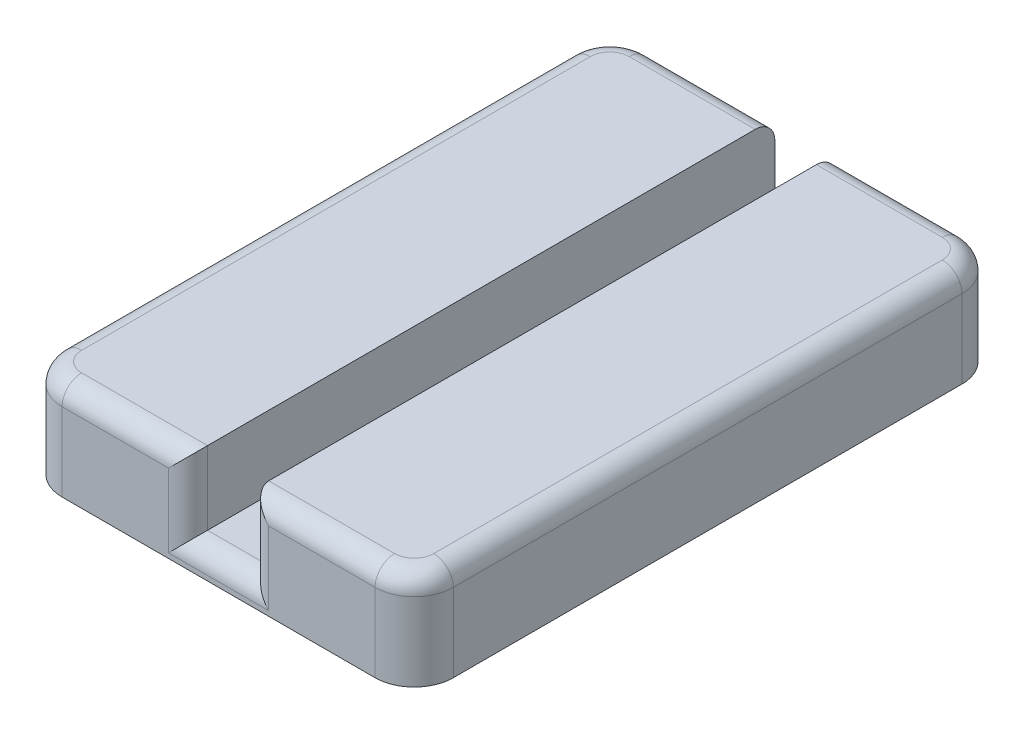
from build123d import *

# Parameters (mm, degrees)
BOSS_EXTRUDE1_DEPTH = 6.35
SKETCH2_W           = 3.96875
SKETCH2_H           = 31.75
CUT_EXTRUDE1_DEPTH  = 4.7625
FILLET1_R           = 1.27
SKETCH3_W           = 4.462087674
SKETCH3_H           = 1.522359324
SKETCH3_W_2         = 4.462087673
CUT_EXTRUDE2_DEPTH  = 0.79375


with BuildPart() as part:
    # Sketch1 → Boss-Extrude1 (new body)
    with BuildSketch(Plane(origin=(0, 0, 0), x_dir=(1, 0, 0), z_dir=(0, 1, 0))):
        with BuildLine():
            Line((14.684375, 38.1), (22.86, 38.1))
            ThreePointArc((22.86, 38.1), (24.656051224, 37.356051224), (25.4, 35.56))
            Line((25.4, 35.56), (25.4, 2.54))
            ThreePointArc((25.4, 2.54), (24.656051224, 0.743948776), (22.86, 0))
            Line((22.86, 0), (2.54, 0))
            ThreePointArc((2.54, 0), (0.743948776, 0.743948776), (0, 2.54))
            Line((0, 2.54), (0, 35.56))
            ThreePointArc((0, 35.56), (0.743948776, 37.356051224), (2.54, 38.1))
            Line((2.54, 38.1), (10.715625, 38.1))
            Line((10.715625, 38.1), (10.715625, 31.75))
            Line((10.715625, 31.75), (14.684375, 31.75))
            Line((14.684375, 31.75), (14.684375, 38.1))
        make_face()
    extrude(amount=BOSS_EXTRUDE1_DEPTH)

    # Sketch2 → Cut-Extrude1 (cut)
    with BuildSketch(Plane(origin=(0, 6.35, 0), x_dir=(1, 0, 0), z_dir=(0, 1, 0))):
        with Locations((12.7, 15.875)):
            Rectangle(SKETCH2_W, SKETCH2_H)
    extrude(amount=-CUT_EXTRUDE1_DEPTH, mode=Mode.SUBTRACT)

    # Fillet1
    fillet1_edges = [part.edges().sort_by_distance(p)[0] for p in [
        (0.743948776, 6.35, -37.356051224),
        (6.6278125, 6.35, -38.1),
        (18.7721875, 6.35, -38.1),
        (18.7721875, 6.35, 0),
        (24.656051224, 6.35, -37.356051224),
        (10.715625, 3.96875, 0),
        (12.7, 1.5875, -31.75),
        (25.4, 6.35, -19.05),
        (12.7, 1.5875, 0),
        (14.684375, 3.96875, 0),
        (24.656051224, 6.35, -0.743948776),
        (6.6278125, 6.35, 0),
        (0.743948776, 6.35, -0.743948776),
        (0, 6.35, -19.05),
    ]]
    fillet(fillet1_edges, radius=FILLET1_R)

    # Sketch3 → Cut-Extrude2 (cut)
    with BuildSketch(Plane.XZ):
        with BuildLine():
            add(Edge.make_bspline(
                [(20.770912427, -33.576184894), (20.716776575, -33.575961936), (20.612603721, -33.5755329), (20.46221534, -33.574104371), (20.324123043, -33.570966146), (20.198357128, -33.565906255), (20.0851548, -33.56021535), (19.983936013, -33.553953657), (19.895010405, -33.545929307), (19.79312919, -33.533339086), (19.675339314, -33.508045408), (19.542562083, -33.453162316), (19.415773604, -33.377459207), (19.296119441, -33.28060062), (19.187162712, -33.162711763), (19.090314389, -33.025739765), (19.00765376, -32.869592526), (18.939057469, -32.695081183), (18.885695016, -32.503668238), (18.846232758, -32.297148185), (18.823553351, -32.075383853), (18.820384009, -31.922639669), (18.81874907, -31.843844974)],
                knots=[0, 0, 0, 0, 0.000162409, 0.000312521, 0.00045118, 0.000576773, 0.000690111, 0.000791213, 0.000880994, 0.000957909, 0.00109919, 0.001240844, 0.00138686, 0.001540837, 0.001701021, 0.001866932, 0.002042704, 0.002229747, 0.002428381, 0.002637991, 0.002859827, 0.003096198, 0.003096198, 0.003096198, 0.003096198], degree=3))
            add(Edge.make_bspline(
                [(18.81874907, -31.843844974), (18.820056819, -31.768593244), (18.822606968, -31.621850102), (18.845623822, -31.407818714), (18.880613937, -31.205347102), (18.932464861, -31.015691402), (18.997496906, -30.84012306), (19.079619825, -30.682160196), (19.174340805, -30.540767403), (19.285724344, -30.420603753), (19.405691262, -30.319794274), (19.531750246, -30.239314331), (19.664152178, -30.183593443), (19.780329143, -30.155581686), (19.881394574, -30.143599817), (19.970235853, -30.134421964), (20.072273761, -30.127228316), (20.186878161, -30.121863165), (20.314552553, -30.116688035), (20.455107258, -30.113589402), (20.608775896, -30.112153355), (20.715409479, -30.111726982), (20.770912427, -30.111505054)],
                knots=[0, 0, 0, 0, 0.000225686, 0.000440094, 0.000645075, 0.00084147, 0.001029153, 0.001205613, 0.001374422, 0.001538129, 0.001695345, 0.001843499, 0.001985023, 0.002124282, 0.002200383, 0.002290243, 0.00239222, 0.002507196, 0.002634428, 0.002775547, 0.00292894, 0.00309545, 0.00309545, 0.00309545, 0.00309545], degree=3))
            Line((20.770912427, -30.111505054), (21.538653983, -30.111505054))
            add(Edge.make_bspline(
                [(21.538653983, -30.111505054), (21.592789272, -30.1117433), (21.697234431, -30.112202958), (21.847630365, -30.113430259), (21.985688596, -30.11718283), (22.111262665, -30.120348252), (22.224650246, -30.12784749), (22.325914729, -30.133573998), (22.414823773, -30.141831713), (22.516437137, -30.154333705), (22.634237386, -30.179638329), (22.766964482, -30.234572303), (22.893767225, -30.30993937), (23.01263834, -30.407659357), (23.122495508, -30.524631734), (23.219175047, -30.662011072), (23.30201392, -30.818059389), (23.370184173, -30.992772567), (23.425311838, -31.183754367), (23.462628775, -31.390734149), (23.487442826, -31.612207153), (23.489669148, -31.765029295), (23.49081734, -31.843844974)],
                knots=[0, 0, 0, 0, 0.000162409, 0.000313341, 0.00045118, 0.000576743, 0.000690126, 0.000792047, 0.000881011, 0.000957926, 0.001099207, 0.001240861, 0.001386877, 0.001540217, 0.001700961, 0.001866872, 0.002042644, 0.002229686, 0.002428546, 0.002638004, 0.002859926, 0.003096269, 0.003096269, 0.003096269, 0.003096269], degree=3))
            add(Edge.make_bspline(
                [(23.49081734, -31.843844974), (23.489480685, -31.919091495), (23.486874166, -32.065824479), (23.464252931, -32.279976538), (23.427779674, -32.482498911), (23.376439542, -32.672201529), (23.31202572, -32.84792467), (23.229956548, -33.005552517), (23.13497101, -33.146965677), (23.024088338, -33.267830417), (22.90410273, -33.36883421), (22.77756224, -33.448224732), (22.645212955, -33.504309591), (22.528668317, -33.532039525), (22.427622747, -33.544046719), (22.339061884, -33.553321076), (22.237291771, -33.560450689), (22.122688525, -33.565830216), (21.995013771, -33.571000841), (21.854459179, -33.574100872), (21.700790507, -33.5755365), (21.594156928, -33.575962934), (21.538653983, -33.576184894)],
                knots=[0, 0, 0, 0, 0.000225686, 0.000440094, 0.000645221, 0.000842407, 0.001029034, 0.001205493, 0.001374303, 0.001538614, 0.001695831, 0.001843551, 0.001985074, 0.002125131, 0.002201232, 0.002290275, 0.002392252, 0.002507229, 0.002634461, 0.00277558, 0.002928973, 0.003095483, 0.003095483, 0.003095483, 0.003095483], degree=3))
            Line((21.538653983, -33.576184894), (20.770912427, -33.576184894))
        make_face()
        with BuildLine():
            add(Edge.make_bspline(
                [(22.26128252, -32.05382557), (22.286435978, -32.053591122), (22.334560789, -32.053142563), (22.403226389, -32.051892174), (22.464729911, -32.048317769), (22.519234309, -32.044687332), (22.566509651, -32.038727219), (22.606928031, -32.032740878), (22.639778769, -32.024473408), (22.673717551, -32.013260872), (22.707498513, -31.991035252), (22.736526032, -31.95322813), (22.753120401, -31.904697385), (22.754917642, -31.869406837), (22.755885253, -31.850406868)],
                knots=[0, 0, 0, 0, 7.5466e-05, 0.000144386, 0.000205991, 0.000260282, 0.000308201, 0.000348924, 0.000382743, 0.000409724, 0.000455906, 0.000501516, 0.00055029, 0.000607177, 0.000607177, 0.000607177, 0.000607177], degree=3))
            add(Edge.make_bspline(
                [(22.755885253, -31.850406868), (22.755326946, -31.833882053), (22.75425251, -31.802080759), (22.739635876, -31.757814511), (22.716894598, -31.719273361), (22.689616874, -31.692223987), (22.659716096, -31.674567567), (22.628265635, -31.663610736), (22.588216067, -31.655247606), (22.53988565, -31.646593098), (22.482505713, -31.641864236), (22.416676993, -31.636291142), (22.341948057, -31.634384162), (22.289169395, -31.634044072), (22.26128252, -31.633864378)],
                knots=[0, 0, 0, 0, 4.9385e-05, 9.5039e-05, 0.000138084, 0.000182747, 0.00020849, 0.000241707, 0.000282099, 0.000331183, 0.000388886, 0.000454689, 0.000529371, 0.00061304, 0.00061304, 0.00061304, 0.00061304], degree=3))
            Line((22.26128252, -31.633864378), (20.136049218, -31.633864378))
            add(Edge.make_bspline(
                [(20.136049218, -31.633864378), (20.104605962, -31.634064235), (20.044722883, -31.634444859), (19.959685902, -31.636122178), (19.884194165, -31.63830417), (19.818233914, -31.642115634), (19.761979213, -31.648274489), (19.714786702, -31.653439147), (19.67703549, -31.660337321), (19.640585394, -31.671757801), (19.603987984, -31.69226679), (19.573494103, -31.731405445), (19.556167712, -31.782636525), (19.554555924, -31.820185205), (19.553681158, -31.840564027)],
                knots=[0, 0, 0, 0, 9.4331e-05, 0.000179651, 0.000255153, 0.0003209, 0.000377787, 0.000424892, 0.000463338, 0.000492649, 0.000539352, 0.000586621, 0.000637989, 0.000698957, 0.000698957, 0.000698957, 0.000698957], degree=3))
            add(Edge.make_bspline(
                [(19.553681158, -31.840564027), (19.554596703, -31.861570568), (19.556302052, -31.900698559), (19.577643484, -31.953205458), (19.612242654, -31.99404748), (19.653422657, -32.01502396), (19.694324836, -32.026466759), (19.735110971, -32.033051476), (19.784820604, -32.040052409), (19.844044269, -32.044047896), (19.912304124, -32.049825391), (19.990046394, -32.051419493), (20.076708882, -32.053287076), (20.137687702, -32.053640273), (20.169678923, -32.05382557)],
                knots=[0, 0, 0, 0, 6.2682e-05, 0.000116756, 0.000166757, 0.000219977, 0.000252426, 0.000294097, 0.000343747, 0.000403008, 0.000472084, 0.000549225, 0.000636186, 0.000732157, 0.000732157, 0.000732157, 0.000732157], degree=3))
            Line((20.169678923, -32.05382557), (22.26128252, -32.05382557))
        make_face(mode=Mode.SUBTRACT)
        Polygon((23.385827042, -25.250454247), (21.371325695, -24.384284287), (18.923739368, -25.302949396), (18.923739368, -23.780590072), (20.836531364, -23.176895857), (18.923739368, -23.176895857), (18.923739368, -21.654536533), (23.385827042, -21.654536533), (23.385827042, -23.176895857), (21.651846648, -23.176895857), (23.385827042, -23.833085221), align=None)
        with Locations((21.154783205, -15.743582745)):
            Rectangle(SKETCH3_W, SKETCH3_H)
        with BuildLine():
            Line((23.385827042, -9.780133807), (18.923739368, -9.780133807))
            Line((18.923739368, -9.780133807), (18.923739368, -8.467755079))
            Line((18.923739368, -8.467755079), (21.936468785, -8.441507505))
            Line((21.936468785, -8.441507505), (18.923739368, -7.942803588))
            Line((18.923739368, -7.942803588), (18.923739368, -6.997890904))
            Line((18.923739368, -6.997890904), (21.883973636, -6.499186988))
            Line((21.883973636, -6.499186988), (18.923739368, -6.472939413))
            Line((18.923739368, -6.472939413), (18.923739368, -5.160560686))
            Line((18.923739368, -5.160560686), (23.385827042, -5.160560686))
            Line((23.385827042, -5.160560686), (23.385827042, -7.089757415))
            add(Edge.make_bspline(
                [(23.385827042, -7.089757415), (23.318309078, -7.1035023), (23.176495211, -7.13237188), (22.953508843, -7.176159682), (22.710683659, -7.225217529), (22.541834366, -7.257516332), (22.454038146, -7.274310674)],
                knots=[0, 0, 0, 0, 0.000206708, 0.000434166, 0.000681733, 0.000949895, 0.000949895, 0.000949895, 0.000949895], degree=3))
            Line((22.454038146, -7.274310674), (21.302425812, -7.496594821))
            Line((21.302425812, -7.496594821), (23.385827042, -7.850937077))
            Line((23.385827042, -7.850937077), (23.385827042, -9.780133807))
        make_face()
        Polygon((15.246486764, -27.182275734), (10.784399091, -28.061569481), (10.784399091, -26.52608637), (11.571826327, -26.447343646), (11.571826327, -25.896964818), (10.784399091, -25.817401857), (10.784399091, -24.255671171), (15.246486764, -25.056222195), align=None)
        with BuildLine():
            add(Edge.make_bspline(
                [(12.359253564, -26.380904473), (12.426781498, -26.373477212), (12.565649343, -26.358203418), (12.779793896, -26.335543162), (13.005297413, -26.310641017), (13.242351809, -26.285264027), (13.490932554, -26.25920529), (13.750946989, -26.231306761), (14.022390995, -26.201549335), (14.207241941, -26.181814889), (14.30157408, -26.171744114)],
                knots=[0, 0, 0, 0, 0.000203805, 0.000419115, 0.000646019, 0.000884427, 0.001134341, 0.001395847, 0.001668947, 0.001953551, 0.001953551, 0.001953551, 0.001953551], degree=3))
            add(Edge.make_bspline(
                [(14.30157408, -26.171744114), (14.194675726, -26.157210175), (13.98827308, -26.129147599), (13.689629562, -26.089253824), (13.413545668, -26.051336019), (13.159556694, -26.016804025), (12.927972975, -25.985659873), (12.718469889, -25.958013988), (12.531530234, -25.932308773), (12.414213705, -25.916618777), (12.359253564, -25.909268368)],
                knots=[0, 0, 0, 0, 0.000323645, 0.000624905, 0.000903888, 0.001159671, 0.001393882, 0.001604893, 0.001793628, 0.001959976, 0.001959976, 0.001959976, 0.001959976], degree=3))
            Line((12.359253564, -25.909268368), (12.359253564, -26.380904473))
        make_face(mode=Mode.SUBTRACT)
        with Locations((13.015442928, -18.712183426)):
            Rectangle(SKETCH3_W_2, SKETCH3_H)
        with BuildLine():
            Line((15.246486764, -12.801229638), (12.264106106, -12.801229638))
            add(Edge.make_bspline(
                [(12.264106106, -12.801229638), (12.210790584, -12.801294902), (12.1090802, -12.801419407), (11.964169233, -12.80058157), (11.834291543, -12.79910854), (11.719193173, -12.79637604), (11.618837142, -12.794202707), (11.533500932, -12.791216015), (11.463272754, -12.786647777), (11.389700727, -12.782542205), (11.308590966, -12.767161969), (11.218258413, -12.731901255), (11.132913096, -12.679226955), (11.053759106, -12.610009813), (10.982601834, -12.526790657), (10.923336766, -12.430231172), (10.875404435, -12.322750571), (10.846683064, -12.223936638), (10.82836882, -12.137191714), (10.817542114, -12.062848256), (10.806374721, -11.981195351), (10.798741154, -11.891387261), (10.791784886, -11.793791371), (10.788492817, -11.688176589), (10.784497516, -11.574730567), (10.784432651, -11.496510964), (10.784399091, -11.456041442)],
                knots=[0, 0, 0, 0, 0.000159946, 0.00030513, 0.000434738, 0.000549598, 0.000650517, 0.000735884, 0.000805725, 0.000861652, 0.000956884, 0.001051932, 0.001150967, 0.001256217, 0.001366181, 0.001478166, 0.001594928, 0.001718196, 0.001786083, 0.001860792, 0.001943506, 0.002033287, 0.002131115, 0.002237005, 0.002350246, 0.002471643, 0.002471643, 0.002471643, 0.002471643], degree=3))
            Line((10.784399091, -11.456041442), (10.784399091, -10.701423673))
            Line((10.784399091, -10.701423673), (11.527533545, -10.701423673))
            add(Edge.make_bspline(
                [(11.527533545, -10.701423673), (11.526413645, -10.722748559), (11.524346403, -10.762112505), (11.521860789, -10.816521342), (11.520126058, -10.861361092), (11.519573551, -10.888163356), (11.519331178, -10.899920956)],
                knots=[0, 0, 0, 0, 6.4063e-05, 0.000118254, 0.000163397, 0.000198677, 0.000198677, 0.000198677, 0.000198677], degree=3))
            add(Edge.make_bspline(
                [(11.519331178, -10.899920956), (11.520083289, -10.925669557), (11.521507927, -10.974442232), (11.533004626, -11.04341444), (11.551664413, -11.104050639), (11.577514888, -11.156361095), (11.610695752, -11.198240442), (11.647073384, -11.231234576), (11.687344441, -11.25425385), (11.73429174, -11.267249734), (11.792998262, -11.271043826), (11.868918063, -11.276762042), (11.965815981, -11.278322979), (12.03717829, -11.278676596), (12.076271901, -11.278870314)],
                knots=[0, 0, 0, 0, 7.7211e-05, 0.000146253, 0.000209031, 0.00026699, 0.000320154, 0.000368381, 0.000413554, 0.000457945, 0.0005132, 0.000589641, 0.00068646, 0.000803757, 0.000803757, 0.000803757, 0.000803757], degree=3))
            Line((12.076271901, -11.278870314), (15.246486764, -11.278870314))
            Line((15.246486764, -11.278870314), (15.246486764, -12.801229638))
        make_face()
        with BuildLine():
            Line((3.432486049, -33.129976127), (2.645058813, -33.129976127))
            Line((2.645058813, -33.129976127), (2.645058813, -29.927772032))
            Line((2.645058813, -29.927772032), (3.327495751, -29.940895819))
            add(Edge.make_bspline(
                [(3.327495751, -29.940895819), (3.399429279, -29.998006118), (3.539784778, -30.10943878), (3.74464914, -30.272982315), (3.939481015, -30.426710761), (4.123840106, -30.571518769), (4.297383127, -30.707499941), (4.460630816, -30.834610791), (4.613097014, -30.952854536), (4.75539469, -31.061701263), (4.885996928, -31.163241957), (5.007929883, -31.25340017), (5.117294412, -31.337166522), (5.217852743, -31.409690071), (5.306952058, -31.474636208), (5.385734055, -31.530769831), (5.454365072, -31.577136394), (5.529790554, -31.627014801), (5.61484114, -31.678960681), (5.711011266, -31.733167446), (5.802049353, -31.778516595), (5.886559694, -31.816656804), (5.965987107, -31.845320483), (6.039084139, -31.867535358), (6.107096468, -31.880379846), (6.150706175, -31.882307817), (6.171256406, -31.883216336)],
                knots=[0, 0, 0, 0, 0.000275543, 0.000537636, 0.00078641, 0.001020072, 0.001240927, 0.001447826, 0.001640768, 0.001819756, 0.001985292, 0.002137035, 0.002274672, 0.002398538, 0.002508957, 0.002605452, 0.002688717, 0.002757422, 0.002876715, 0.002987614, 0.003088489, 0.003181766, 0.003265579, 0.003341631, 0.003410813, 0.003472468, 0.003472468, 0.003472468, 0.003472468], degree=3))
            add(Edge.make_bspline(
                [(6.171256406, -31.883216336), (6.199479218, -31.882374934), (6.252540381, -31.88079303), (6.326878036, -31.866530823), (6.389537554, -31.840950376), (6.441829504, -31.805875144), (6.482146585, -31.759460725), (6.510564891, -31.702535436), (6.526715641, -31.63528422), (6.528665169, -31.587202226), (6.529699846, -31.561683548)],
                knots=[0, 0, 0, 0, 8.4628e-05, 0.000159107, 0.000225672, 0.00028642, 0.000346297, 0.000407924, 0.000475562, 0.00055206, 0.00055206, 0.00055206, 0.00055206], degree=3))
            add(Edge.make_bspline(
                [(6.529699846, -31.561683548), (6.528810606, -31.536137846), (6.52713027, -31.487865853), (6.508977109, -31.420448031), (6.477904866, -31.363440248), (6.441333847, -31.324754452), (6.405438619, -31.299321446), (6.371528507, -31.284062661), (6.332578224, -31.270372603), (6.287667539, -31.258534275), (6.236458217, -31.251182349), (6.179632118, -31.244129834), (6.116594367, -31.241482256), (6.072827156, -31.240608986), (6.049861374, -31.240150759)],
                knots=[0, 0, 0, 0, 7.6498e-05, 0.000144553, 0.000207332, 0.000269416, 0.000302409, 0.000338732, 0.000380499, 0.000426257, 0.000477768, 0.000535559, 0.000597983, 0.000666902, 0.000666902, 0.000666902, 0.000666902], degree=3))
            Line((6.049861374, -31.240150759), (5.637282312, -31.240150759))
            Line((5.637282312, -31.240150759), (5.637282312, -29.927772032))
            Line((5.637282312, -29.927772032), (5.797228469, -29.927772032))
            add(Edge.make_bspline(
                [(5.797228469, -29.927772032), (5.855201576, -29.928420234), (5.964936505, -29.929647191), (6.119934476, -29.938151251), (6.255554372, -29.953427862), (6.375615504, -29.974772132), (6.485997459, -30.010211191), (6.591707555, -30.063949586), (6.696547595, -30.135473788), (6.798832092, -30.224421187), (6.895672217, -30.329192998), (6.979550397, -30.451355047), (7.051029036, -30.587747802), (7.110172582, -30.738724461), (7.155586408, -30.904890405), (7.189264442, -31.086164635), (7.208598345, -31.283202547), (7.210930946, -31.419739946), (7.212136785, -31.490322954)],
                knots=[0, 0, 0, 0, 0.000173921, 0.000329208, 0.000465442, 0.000583196, 0.000694474, 0.000811856, 0.000937663, 0.001074318, 0.001217719, 0.001364477, 0.001517477, 0.00167878, 0.001849927, 0.002033486, 0.002231325, 0.002443047, 0.002443047, 0.002443047, 0.002443047], degree=3))
            add(Edge.make_bspline(
                [(7.212136785, -31.490322954), (7.211349222, -31.560077807), (7.209824465, -31.695126249), (7.193641135, -31.891176913), (7.169104563, -32.074075225), (7.133041612, -32.24413158), (7.086451567, -32.401055354), (7.030216302, -32.545159516), (6.963463223, -32.67616586), (6.886531946, -32.793498316), (6.801017793, -32.896712328), (6.710302185, -32.987102315), (6.614435174, -33.064023717), (6.512223661, -33.126069885), (6.405009449, -33.175229555), (6.291794588, -33.209154027), (6.173529603, -33.23185466), (6.092622033, -33.233917841), (6.051501848, -33.234966425)],
                knots=[0, 0, 0, 0, 0.000209218, 0.000405056, 0.000589727, 0.000762507, 0.000926, 0.001080296, 0.001225932, 0.001366298, 0.001500305, 0.001627326, 0.001749917, 0.001868083, 0.001985181, 0.002102716, 0.002221933, 0.002345143, 0.002345143, 0.002345143, 0.002345143], degree=3))
            add(Edge.make_bspline(
                [(6.051501848, -33.234966425), (6.0194827, -33.234085764), (5.95470237, -33.232304034), (5.856752552, -33.220511994), (5.757607327, -33.200617972), (5.65676052, -33.173259091), (5.554647755, -33.138330465), (5.451599794, -33.093887412), (5.346873978, -33.043317862), (5.257735739, -32.99442266), (5.182368502, -32.948269403), (5.118286704, -32.904896645), (5.045938243, -32.855190995), (4.966747551, -32.796674338), (4.879771358, -32.731088117), (4.785491538, -32.658010794), (4.683506281, -32.577349549), (4.573981503, -32.489221884), (4.457414883, -32.392695507), (4.332825599, -32.289571889), (4.200557435, -32.17912726), (4.062220958, -32.059489405), (3.914995618, -31.933681432), (3.761465104, -31.798617597), (3.598490847, -31.658264852), (3.488680073, -31.560737194), (3.432486049, -31.510828872)],
                knots=[0, 0, 0, 0, 9.6055e-05, 0.000194337, 0.000295519, 0.000399184, 0.00050761, 0.000618975, 0.000735634, 0.000856412, 0.000923796, 0.001000689, 0.001088515, 0.001187115, 0.001296043, 0.001415319, 0.001544958, 0.001686124, 0.001837041, 0.001998983, 0.002171323, 0.002353972, 0.002547654, 0.002752286, 0.002967414, 0.003192882, 0.003192882, 0.003192882, 0.003192882], degree=3))
            Line((3.432486049, -31.510828872), (3.432486049, -33.129976127))
        make_face()
        with BuildLine():
            add(Edge.make_bspline(
                [(5.138578395, -24.244844047), (5.131242903, -24.270917843), (5.116902428, -24.321890649), (5.090477017, -24.395005112), (5.061179373, -24.463082789), (5.028369663, -24.526134494), (4.991136445, -24.583232773), (4.951918738, -24.636555646), (4.908304836, -24.68388406), (4.860393262, -24.727917102), (4.801541064, -24.766073804), (4.727983349, -24.797518182), (4.638757319, -24.824074837), (4.533337529, -24.845715737), (4.411677009, -24.862543549), (4.273971549, -24.874414808), (4.120197837, -24.881766706), (4.012402424, -24.882567626), (3.955797067, -24.882988203)],
                knots=[0, 0, 0, 0, 8.1237e-05, 0.000158813, 0.000233021, 0.000303465, 0.000371723, 0.000437342, 0.000501786, 0.000564522, 0.000632091, 0.000711043, 0.000803672, 0.000910972, 0.001033583, 0.001171931, 0.001325493, 0.0014953, 0.0014953, 0.0014953, 0.0014953], degree=3))
            add(Edge.make_bspline(
                [(3.955797067, -24.882988203), (3.91313423, -24.882534893), (3.829929123, -24.881650804), (3.708943475, -24.874266481), (3.59506762, -24.862019205), (3.488743863, -24.84515871), (3.389603813, -24.822861807), (3.297873888, -24.796291296), (3.213488485, -24.763964861), (3.135777772, -24.727256632), (3.064053559, -24.683849202), (2.997306956, -24.633814933), (2.935539834, -24.575488562), (2.87738554, -24.510954771), (2.823643734, -24.439140193), (2.77551578, -24.359556996), (2.730309056, -24.273787304), (2.690020453, -24.180558753), (2.655041513, -24.0800696), (2.624009802, -23.973037277), (2.597547493, -23.858888396), (2.57667969, -23.738082012), (2.560113893, -23.610288356), (2.5491797, -23.475880249), (2.541332292, -23.334746733), (2.540495939, -23.238425184), (2.540068515, -23.189199408)],
                knots=[0, 0, 0, 0, 0.000127981, 0.0002496, 0.000363459, 0.000471472, 0.000572361, 0.000668133, 0.000757704, 0.000843186, 0.000925618, 0.001008791, 0.00109294, 0.001180063, 0.001269141, 0.001361566, 0.001458791, 0.001559816, 0.001665919, 0.001777799, 0.001893995, 0.002017249, 0.00214544, 0.002280448, 0.002421722, 0.002569385, 0.002569385, 0.002569385, 0.002569385], degree=3))
            add(Edge.make_bspline(
                [(2.540068515, -23.189199408), (2.540354581, -23.13340737), (2.540911699, -23.024751742), (2.55058265, -22.866646261), (2.563977489, -22.717715958), (2.583610623, -22.57809078), (2.60875769, -22.447403424), (2.639974143, -22.326145647), (2.675553829, -22.213662665), (2.718388341, -22.111143069), (2.765967049, -22.017759746), (2.813081767, -21.931149684), (2.865811002, -21.854602931), (2.919197104, -21.785290799), (2.976617305, -21.725219032), (3.034909105, -21.672003368), (3.097591917, -21.629363116), (3.163020493, -21.592486358), (3.236992898, -21.563815225), (3.320838652, -21.538405351), (3.416891587, -21.517545823), (3.524849877, -21.500711777), (3.644405211, -21.486765352), (3.776033641, -21.477217468), (3.919653937, -21.471460368), (4.019496263, -21.471028329), (4.071450442, -21.470803512)],
                knots=[0, 0, 0, 0, 0.000167346, 0.000325909, 0.000475025, 0.000615848, 0.000748721, 0.000874054, 0.000991299, 0.001102347, 0.001206891, 0.001305681, 0.001397818, 0.001485441, 0.001567833, 0.001646849, 0.001721706, 0.001794763, 0.001871681, 0.001959124, 0.002057433, 0.002166256, 0.002286819, 0.002418426, 0.002562082, 0.002717936, 0.002717936, 0.002717936, 0.002717936], degree=3))
            Line((4.071450442, -21.470803512), (4.429893882, -21.470803512))
            Line((4.429893882, -21.470803512), (4.429893882, -22.940667686))
            Line((4.429893882, -22.940667686), (3.682658244, -22.940667686))
            add(Edge.make_bspline(
                [(3.682658244, -22.940667686), (3.658872599, -22.940918548), (3.613756291, -22.94139438), (3.549163093, -22.942423801), (3.491480311, -22.946842777), (3.440624233, -22.951738971), (3.396352744, -22.956881897), (3.359201171, -22.96523636), (3.328228019, -22.97387771), (3.29634914, -22.987591014), (3.264205017, -23.01439543), (3.240097157, -23.060870194), (3.224173733, -23.119259677), (3.223096901, -23.162815677), (3.222505453, -23.186738698)],
                knots=[0, 0, 0, 0, 7.1365e-05, 0.000135365, 0.000193746, 0.000244838, 0.000288688, 0.0003273, 0.000358962, 0.000385029, 0.000431029, 0.000480982, 0.000539685, 0.000611215, 0.000611215, 0.000611215, 0.000611215], degree=3))
            add(Edge.make_bspline(
                [(3.222505453, -23.186738698), (3.223571398, -23.212853478), (3.225535859, -23.260981161), (3.244338553, -23.326551222), (3.275939846, -23.378709305), (3.315543095, -23.409892014), (3.356475409, -23.425193682), (3.396918588, -23.436932992), (3.447890338, -23.445142606), (3.508673176, -23.452213421), (3.579457832, -23.459185411), (3.66048317, -23.462664572), (3.751540658, -23.465244114), (3.815534044, -23.465489967), (3.849166295, -23.465619177)],
                knots=[0, 0, 0, 0, 7.8198e-05, 0.000144114, 0.000202368, 0.000258481, 0.000291229, 0.000333029, 0.000384677, 0.000445822, 0.000516667, 0.000597974, 0.000689054, 0.000789946, 0.000789946, 0.000789946, 0.000789946], degree=3))
            Line((3.849166295, -23.465619177), (4.162496717, -23.465619177))
            add(Edge.make_bspline(
                [(4.162496717, -23.465619177), (4.203018437, -23.464841959), (4.278630864, -23.463391691), (4.38321784, -23.448798803), (4.471041066, -23.426107357), (4.542771821, -23.392118346), (4.599275655, -23.346732875), (4.645654152, -23.293481386), (4.680041742, -23.230054004), (4.69980403, -23.170134417), (4.711376642, -23.114786116), (4.719466026, -23.063612114), (4.725664552, -23.00334823), (4.731397441, -22.934434689), (4.73619737, -22.856763473), (4.740232987, -22.770082525), (4.743706512, -22.674662159), (4.74446834, -22.60792837), (4.744864777, -22.573201643)],
                knots=[0, 0, 0, 0, 0.000121495, 0.000226706, 0.000316055, 0.000392724, 0.000462796, 0.000532012, 0.000603236, 0.000677679, 0.000720473, 0.000772795, 0.000833031, 0.000902169, 0.000980247, 0.00106647, 0.001162493, 0.001266676, 0.001266676, 0.001266676, 0.001266676], degree=3))
            Line((4.744864777, -22.573201643), (5.374806566, -22.573201643))
            add(Edge.make_bspline(
                [(5.374806566, -22.573201643), (5.375109078, -22.615306974), (5.375684638, -22.69541665), (5.376053169, -22.809167558), (5.378281238, -22.910088556), (5.382839594, -22.998368237), (5.38661743, -23.074135847), (5.391032508, -23.137407544), (5.397588944, -23.187760041), (5.406637877, -23.237192235), (5.424098074, -23.287573852), (5.454821224, -23.338221896), (5.494283595, -23.380846324), (5.544928431, -23.413804965), (5.607943489, -23.437252275), (5.684134259, -23.453769457), (5.774792476, -23.464336368), (5.840121004, -23.465171415), (5.875150956, -23.465619177)],
                knots=[0, 0, 0, 0, 0.000126319, 0.000240335, 0.000341254, 0.000429115, 0.000505507, 0.000568857, 0.00061932, 0.000657766, 0.000719508, 0.000778027, 0.000834313, 0.000892324, 0.000957516, 0.001034919, 0.001125773, 0.001230815, 0.001230815, 0.001230815, 0.001230815], degree=3))
            Line((5.875150956, -23.465619177), (6.132705281, -23.465619177))
            add(Edge.make_bspline(
                [(6.132705281, -23.465619177), (6.169642092, -23.464875318), (6.237168803, -23.463515416), (6.328226661, -23.453215576), (6.399477393, -23.434597813), (6.452631863, -23.406395325), (6.488263339, -23.366915733), (6.51343926, -23.320955222), (6.527155583, -23.265412859), (6.528813317, -23.22590962), (6.529699846, -23.204783905)],
                knots=[0, 0, 0, 0, 0.000110808, 0.000202575, 0.000274232, 0.000330799, 0.000380129, 0.000431517, 0.000486626, 0.000549975, 0.000549975, 0.000549975, 0.000549975], degree=3))
            add(Edge.make_bspline(
                [(6.529699846, -23.204783905), (6.52907982, -23.181415384), (6.52792307, -23.137817957), (6.511318533, -23.078418389), (6.485103931, -23.029895885), (6.452292128, -23.000257542), (6.420135421, -22.98272414), (6.389639876, -22.971668563), (6.353396686, -22.962009474), (6.311249688, -22.953576561), (6.262892274, -22.948688464), (6.208824587, -22.943169742), (6.148576457, -22.941178204), (6.106456997, -22.94084361), (6.084311316, -22.940667686)],
                knots=[0, 0, 0, 0, 6.9894e-05, 0.000130397, 0.000183301, 0.000233234, 0.000260401, 0.00029285, 0.000330258, 0.000372887, 0.00042162, 0.000475979, 0.000535907, 0.000602351, 0.000602351, 0.000602351, 0.000602351], degree=3))
            Line((6.084311316, -22.940667686), (5.689777461, -22.940667686))
            Line((5.689777461, -22.940667686), (5.689777461, -21.470803512))
            Line((5.689777461, -21.470803512), (6.084311316, -21.470803512))
            add(Edge.make_bspline(
                [(6.084311316, -21.470803512), (6.137415619, -21.471711889), (6.239311826, -21.473454879), (6.385344694, -21.49199492), (6.518197352, -21.520532219), (6.637474391, -21.562600222), (6.743680661, -21.615941107), (6.83694602, -21.681284975), (6.917027013, -21.759035866), (6.982086586, -21.850853477), (7.037769816, -21.954255608), (7.083477928, -22.0714729), (7.123920325, -22.201578944), (7.156329872, -22.345884706), (7.181394349, -22.503987911), (7.198846243, -22.676244038), (7.210882888, -22.86202766), (7.21170968, -22.990681275), (7.212136785, -23.057141299)],
                knots=[0, 0, 0, 0, 0.000159229, 0.000305529, 0.000440848, 0.000566151, 0.000683903, 0.000796323, 0.000906528, 0.001016947, 0.001132553, 0.00125806, 0.001393747, 0.00154099, 0.001701325, 0.001873702, 0.002060249, 0.002259594, 0.002259594, 0.002259594, 0.002259594], degree=3))
            add(Edge.make_bspline(
                [(7.212136785, -23.057141299), (7.211245813, -23.140004705), (7.209538763, -23.298766017), (7.195222212, -23.526640685), (7.169709483, -23.733593566), (7.136534205, -23.920344775), (7.091574171, -24.08619399), (7.037081443, -24.231627487), (6.972924382, -24.356948419), (6.896896289, -24.461749331), (6.811063419, -24.548427467), (6.72011854, -24.624996295), (6.61975804, -24.688474428), (6.511589468, -24.739967687), (6.396369349, -24.781564747), (6.272985548, -24.809811393), (6.141967812, -24.827447658), (6.051834068, -24.829460081), (6.005568592, -24.830493054)],
                knots=[0, 0, 0, 0, 0.00024858, 0.000476265, 0.000684523, 0.000873877, 0.001044805, 0.001199273, 0.001339056, 0.001465877, 0.001585949, 0.001704202, 0.001821843, 0.001941074, 0.002063011, 0.002188552, 0.002320103, 0.002458842, 0.002458842, 0.002458842, 0.002458842], degree=3))
            add(Edge.make_bspline(
                [(6.005568592, -24.830493054), (5.974653858, -24.830378148), (5.914934298, -24.830156177), (5.828789585, -24.822834822), (5.749123927, -24.81407256), (5.67646429, -24.798551833), (5.610055399, -24.781352612), (5.550291098, -24.758788211), (5.496829844, -24.733114647), (5.449659882, -24.701859154), (5.40686187, -24.665139099), (5.36524056, -24.62363674), (5.324827553, -24.575475538), (5.285736908, -24.521245902), (5.247003066, -24.461085635), (5.209439435, -24.394844243), (5.173362926, -24.322016172), (5.150443493, -24.271167668), (5.138578395, -24.244844047)],
                knots=[0, 0, 0, 0, 9.2701e-05, 0.000179076, 0.000259245, 0.000332921, 0.000401767, 0.00046484, 0.000524266, 0.00057932, 0.000634036, 0.000693196, 0.000755474, 0.000822413, 0.000893627, 0.000970032, 0.001050733, 0.001137353, 0.001137353, 0.001137353, 0.001137353], degree=3))
        make_face()
        Polygon((7.212136785, -16.651584777), (2.540068515, -14.920065093), (2.540068515, -13.827509802), (7.212136785, -15.559849723), align=None)
        with BuildLine():
            Line((7.107146486, -8.70398325), (6.372214399, -8.70398325))
            Line((6.372214399, -8.70398325), (6.372214399, -6.919148181))
            Line((6.372214399, -6.919148181), (5.592169293, -6.919148181))
            add(Edge.make_bspline(
                [(5.592169293, -6.919148181), (5.616883013, -6.94734616), (5.666013057, -7.003402795), (5.727999022, -7.096430618), (5.78233014, -7.194126675), (5.824279234, -7.298932453), (5.858300238, -7.40887593), (5.883135172, -7.524906385), (5.896742424, -7.64719038), (5.898741598, -7.730603881), (5.899758057, -7.77301459)],
                knots=[0, 0, 0, 0, 0.000112372, 0.000223393, 0.000334613, 0.000447176, 0.000561334, 0.000679576, 0.000802584, 0.000929816, 0.000929816, 0.000929816, 0.000929816], degree=3))
            add(Edge.make_bspline(
                [(5.899758057, -7.77301459), (5.898903588, -7.820605253), (5.897241163, -7.913196051), (5.886354159, -8.047621712), (5.86548851, -8.172782049), (5.838007751, -8.289266035), (5.802012849, -8.396596322), (5.758570617, -8.495658295), (5.705949054, -8.584870749), (5.645639583, -8.666459998), (5.572897363, -8.738502639), (5.485610798, -8.800345283), (5.383319122, -8.851741927), (5.266930001, -8.894390834), (5.135619999, -8.926464411), (4.990016366, -8.950086195), (4.82960642, -8.963688503), (4.717823095, -8.965509742), (4.65956016, -8.966458996)],
                knots=[0, 0, 0, 0, 0.00014278, 0.000277788, 0.000404139, 0.000523107, 0.000636458, 0.000743309, 0.000846987, 0.000946564, 0.001046905, 0.001152744, 0.001266097, 0.001389365, 0.001523846, 0.001670963, 0.001831516, 0.002006296, 0.002006296, 0.002006296, 0.002006296], degree=3))
            Line((4.65956016, -8.966458996), (4.02715766, -8.966458996))
            add(Edge.make_bspline(
                [(4.02715766, -8.966458996), (3.989152837, -8.966291091), (3.915868725, -8.965967324), (3.809743009, -8.963793939), (3.711576031, -8.958735495), (3.621047848, -8.952262389), (3.538418934, -8.944248778), (3.463472523, -8.934355911), (3.396261317, -8.92338664), (3.317165716, -8.904807498), (3.225022223, -8.872806607), (3.119998142, -8.818542765), (3.019882109, -8.74698657), (2.923230024, -8.660174323), (2.834913416, -8.55421564), (2.758036972, -8.429046519), (2.691646335, -8.285810671), (2.635959706, -8.124294843), (2.593062522, -7.943753204), (2.562590892, -7.744882849), (2.543588281, -7.527310218), (2.541274003, -7.376061523), (2.540068515, -7.297277302)],
                knots=[0, 0, 0, 0, 0.000114016, 0.000219855, 0.000318406, 0.000408871, 0.00049212, 0.000567407, 0.00063564, 0.000696321, 0.000810978, 0.00092727, 0.001049702, 0.001179198, 0.00131604, 0.001461934, 0.001618619, 0.001788786, 0.001973603, 0.002174533, 0.002391895, 0.002628215, 0.002628215, 0.002628215, 0.002628215], degree=3))
            add(Edge.make_bspline(
                [(2.540068515, -7.297277302), (2.540512026, -7.25215245), (2.5413889, -7.162935228), (2.549209165, -7.031367417), (2.56029339, -6.903808928), (2.576837031, -6.780396836), (2.597886303, -6.661012326), (2.624299947, -6.54552213), (2.655417793, -6.434452714), (2.690337735, -6.327727227), (2.730209418, -6.227005408), (2.775307584, -6.133176748), (2.825368981, -6.046704249), (2.880168287, -5.967876328), (2.939636178, -5.896959929), (3.003037537, -5.832894142), (3.071960825, -5.77731889), (3.146291846, -5.728673225), (3.228362217, -5.68722957), (3.319520303, -5.651352801), (3.421062432, -5.621047741), (3.53303901, -5.596964008), (3.655123735, -5.577265202), (3.787392698, -5.563681495), (3.929714187, -5.555365669), (4.027965643, -5.554646588), (4.078832573, -5.554274304)],
                knots=[0, 0, 0, 0, 0.000135361, 0.000267626, 0.00039528, 0.000519404, 0.000641043, 0.000758838, 0.000874662, 0.000986975, 0.001095575, 0.001199396, 0.001299, 0.001395023, 0.001487022, 0.001576341, 0.001664987, 0.001752122, 0.001842363, 0.001940301, 0.002045656, 0.00215989, 0.002283681, 0.002416473, 0.002558611, 0.002711194, 0.002711194, 0.002711194, 0.002711194], degree=3))
            Line((4.078832573, -5.554274304), (4.324903584, -5.554274304))
            Line((4.324903584, -5.554274304), (4.324903584, -6.97164333))
            Line((4.324903584, -6.97164333), (4.039461211, -6.97164333))
            add(Edge.make_bspline(
                [(4.039461211, -6.97164333), (4.003917765, -6.971877168), (3.935288034, -6.972328678), (3.836288531, -6.973618459), (3.745249465, -6.977182488), (3.662359435, -6.980929893), (3.58767093, -6.986551505), (3.52095712, -6.994011716), (3.462174929, -7.002278201), (3.410520464, -7.010354093), (3.365808056, -7.023404366), (3.327038587, -7.042275728), (3.294619808, -7.068287479), (3.267584187, -7.100179496), (3.247281454, -7.138608878), (3.232188056, -7.182831427), (3.224660357, -7.233322389), (3.223246616, -7.26882303), (3.222505453, -7.287434461)],
                knots=[0, 0, 0, 0, 0.000106634, 0.000205896, 0.000297001, 0.000379947, 0.000454809, 0.000521657, 0.000581281, 0.00063293, 0.00067834, 0.000720524, 0.000761388, 0.000802137, 0.00084508, 0.000890991, 0.000941694, 0.000997566, 0.000997566, 0.000997566, 0.000997566], degree=3))
            add(Edge.make_bspline(
                [(3.222505453, -7.287434461), (3.223047248, -7.304723033), (3.224088976, -7.337964403), (3.234462664, -7.385089293), (3.24933866, -7.427894437), (3.272704708, -7.463841915), (3.299508449, -7.492669999), (3.326849507, -7.515917749), (3.355878223, -7.531462402), (3.383585075, -7.536975778), (3.412217975, -7.538883903), (3.446173031, -7.539060516), (3.492624228, -7.541254134), (3.551692112, -7.542628771), (3.623324592, -7.544304485), (3.707536809, -7.545923376), (3.804051612, -7.547552664), (3.872679512, -7.548557523), (3.909043575, -7.54908997)],
                knots=[0, 0, 0, 0, 5.1779e-05, 9.9557e-05, 0.000144198, 0.000186976, 0.000227034, 0.000262007, 0.000294289, 0.000324538, 0.000345927, 0.000380387, 0.00042635, 0.00048543, 0.000557629, 0.000641309, 0.000738111, 0.000847215, 0.000847215, 0.000847215, 0.000847215], degree=3))
            Line((3.909043575, -7.54908997), (4.787517086, -7.54908997))
            add(Edge.make_bspline(
                [(4.787517086, -7.54908997), (4.825844031, -7.548545129), (4.896207825, -7.547544866), (4.991783516, -7.534803352), (5.068375439, -7.514903467), (5.12728604, -7.484078388), (5.169119746, -7.440727896), (5.198345371, -7.387639127), (5.214441321, -7.322787366), (5.216314568, -7.276315012), (5.217321119, -7.251344046)],
                knots=[0, 0, 0, 0, 0.000114906, 0.000210955, 0.000288583, 0.000351362, 0.000407624, 0.000466738, 0.000531199, 0.000606061, 0.000606061, 0.000606061, 0.000606061], degree=3))
            add(Edge.make_bspline(
                [(5.217321119, -7.251344046), (5.21697281, -7.234897626), (5.216306091, -7.203416546), (5.207763386, -7.158146317), (5.194140891, -7.117145986), (5.169555582, -7.070989353), (5.134701396, -7.025225601), (5.088771179, -6.992526911), (5.042487289, -6.98136815), (4.992790618, -6.975272072), (4.926696723, -6.972906119), (4.877192832, -6.972092589), (4.849855075, -6.97164333)],
                knots=[0, 0, 0, 0, 4.9276e-05, 9.4322e-05, 0.000137639, 0.000178363, 0.000250739, 0.00030875, 0.000342778, 0.000392427, 0.000458948, 0.000540988, 0.000540988, 0.000540988, 0.000540988], degree=3))
            Line((4.849855075, -6.97164333), (4.849855075, -5.606769453))
            Line((4.849855075, -5.606769453), (7.107146486, -5.659264602))
            Line((7.107146486, -5.659264602), (7.107146486, -8.70398325))
        make_face()
    extrude(amount=-CUT_EXTRUDE2_DEPTH, mode=Mode.SUBTRACT)


solid = part.part
